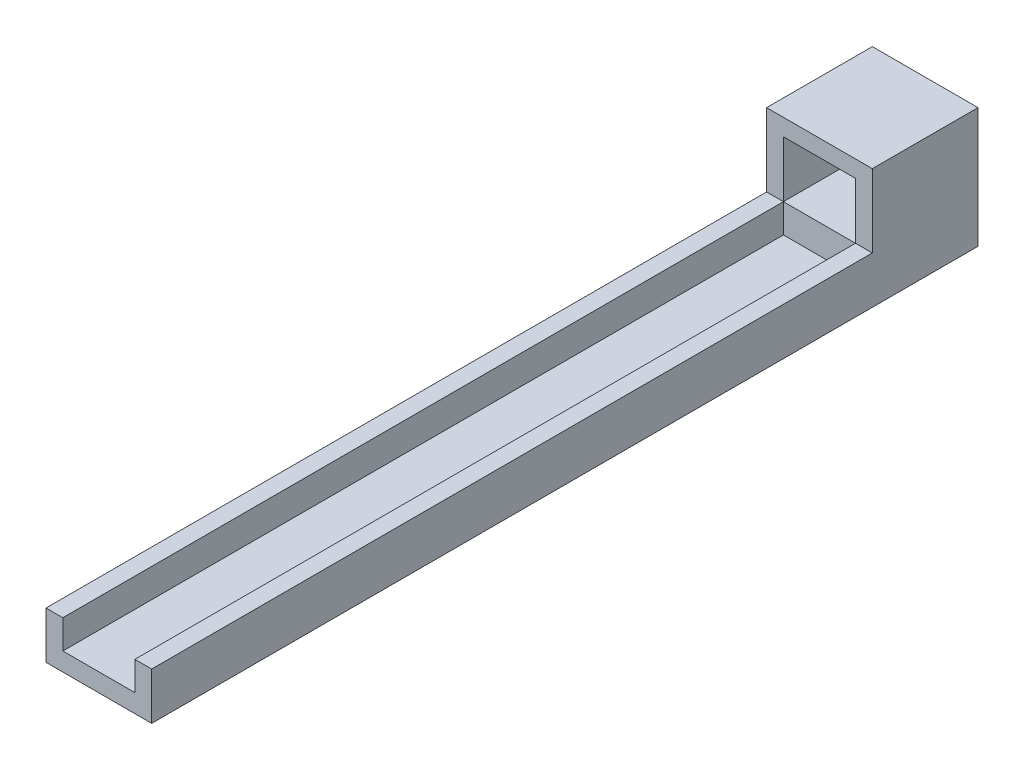
from build123d import *

# Parameters (mm, degrees)
SKETCH_2_W          = 22
SKETCH_2_H          = 25
SKETCH_2_W_2        = 15
SKETCH_2_H_2        = 11.7
EXTRUDE_1_DEPTH     = 22
SKETCH_3_W          = 22
SKETCH_3_H          = 9.8
EXTRUDE_2_DEPTH     = 150
SKETCH_4_W          = 15
SKETCH_4_H          = 150
CUT_EXTRUDE_1_DEPTH = 6


with BuildPart() as part:
    # 草圖2 → 填料-伸長1 (new body)
    with BuildSketch(Plane.XY):
        with Locations((-14.61342143, -7.059615385)):
            Rectangle(SKETCH_2_W, SKETCH_2_H)
        with Locations((-14.61342143, -3.909615385)):
            Rectangle(SKETCH_2_W_2, SKETCH_2_H_2, mode=Mode.SUBTRACT)
    extrude(amount=EXTRUDE_1_DEPTH)

    # 草圖3 → 填料-伸長2 (add)
    with BuildSketch(Plane.XY.offset(22)):
        with Locations((-14.61342143, -14.659615385)):
            Rectangle(SKETCH_3_W, SKETCH_3_H)
    extrude(amount=EXTRUDE_2_DEPTH)

    # 草圖4 → 除料-伸長1 (cut)
    with BuildSketch(Plane(origin=(0, -9.759615385, 0), x_dir=(1, 0, 0), z_dir=(0, 1, 0))):
        with Locations((-14.61342143, -97)):
            Rectangle(SKETCH_4_W, SKETCH_4_H)
    extrude(amount=-CUT_EXTRUDE_1_DEPTH, mode=Mode.SUBTRACT)


solid = part.part
